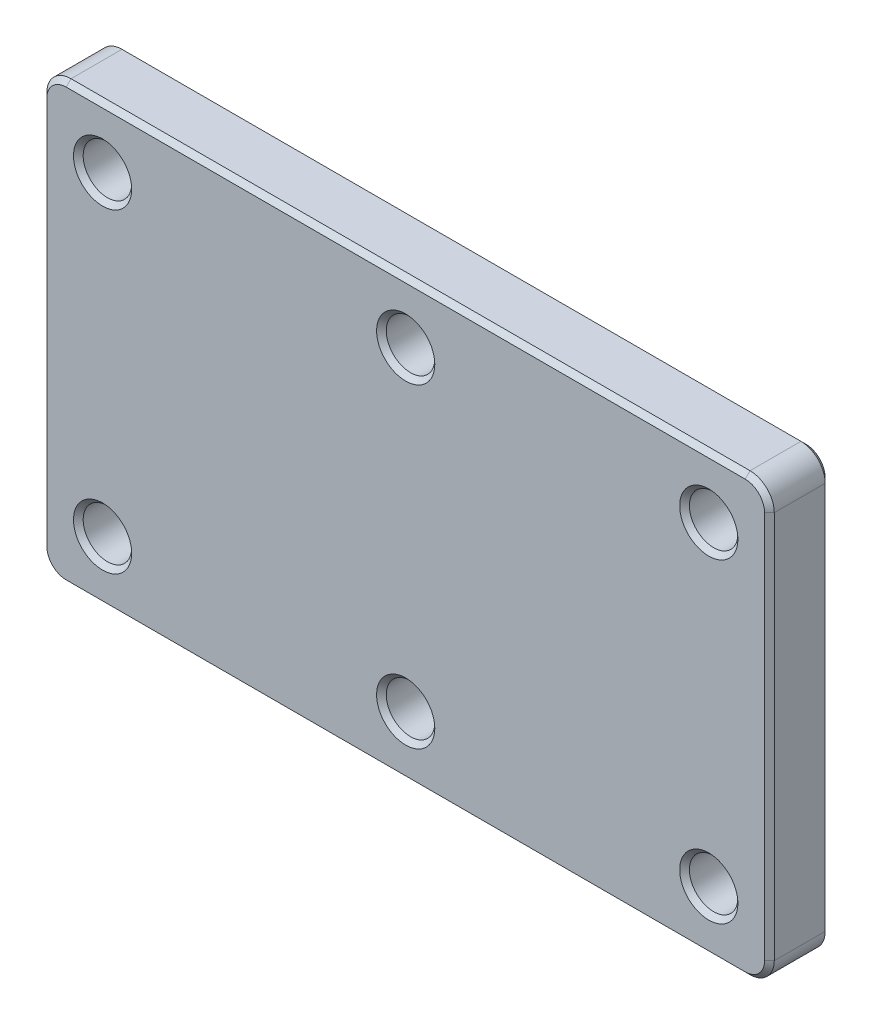
from build123d import *

# Parameters (mm, degrees)
SKETCH1_R           = 10
BOSS_EXTRUDE1_DEPTH = 25
CHAMFER1_SIZE       = 2


with BuildPart() as part:
    # Sketch1 → Boss-Extrude1 (new body)
    with BuildSketch(Plane.XY):
        with BuildLine():
            Line((-140, 90), (140, 90))
            ThreePointArc((140, 90), (147.071067812, 87.071067812), (150, 80))
            Line((150, 80), (150, -80))
            ThreePointArc((150, -80), (147.071067812, -87.071067812), (140, -90))
            Line((140, -90), (-140, -90))
            ThreePointArc((-140, -90), (-147.071067812, -87.071067812), (-150, -80))
            Line((-150, -80), (-150, 80))
            ThreePointArc((-150, 80), (-147.071067812, 87.071067812), (-140, 90))
        make_face()
        with Locations((-125, -65)):
            Circle(SKETCH1_R, mode=Mode.SUBTRACT)
        with Locations((0, -65)):
            Circle(SKETCH1_R, mode=Mode.SUBTRACT)
        with Locations((125, -65)):
            Circle(SKETCH1_R, mode=Mode.SUBTRACT)
        with Locations((125, 65)):
            Circle(SKETCH1_R, mode=Mode.SUBTRACT)
        with Locations((0, 65)):
            Circle(SKETCH1_R, mode=Mode.SUBTRACT)
        with Locations((-125, 65)):
            Circle(SKETCH1_R, mode=Mode.SUBTRACT)
    extrude(amount=-BOSS_EXTRUDE1_DEPTH)

    # Chamfer1
    chamfer1_edges = [part.edges().sort_by_distance(p)[0] for p in [
        (150, 0, 0),
        (147.071067812, -87.071067812, 0),
        (0, -90, 0),
        (-147.071067812, -87.071067812, 0),
        (147.071067812, -87.071067812, -25),
        (150, 0, -25),
        (147.071067812, 87.071067812, -25),
        (-10, -65, -25),
        (-10, -65, 0),
        (0, 90, -25),
        (-135, -65, -25),
        (-135, -65, 0),
        (-147.071067812, 87.071067812, -25),
        (115, -65, -25),
        (115, -65, 0),
        (-150, 0, -25),
        (115, 65, -25),
        (115, 65, 0),
        (-10, 65, -25),
        (-10, 65, 0),
        (-135, 65, -25),
        (-135, 65, 0),
        (-147.071067812, -87.071067812, -25),
        (-150, 0, 0),
        (0, -90, -25),
        (-147.071067812, 87.071067812, 0),
        (0, 90, 0),
        (147.071067812, 87.071067812, 0),
    ]]
    chamfer(chamfer1_edges, length=CHAMFER1_SIZE)


solid = part.part
